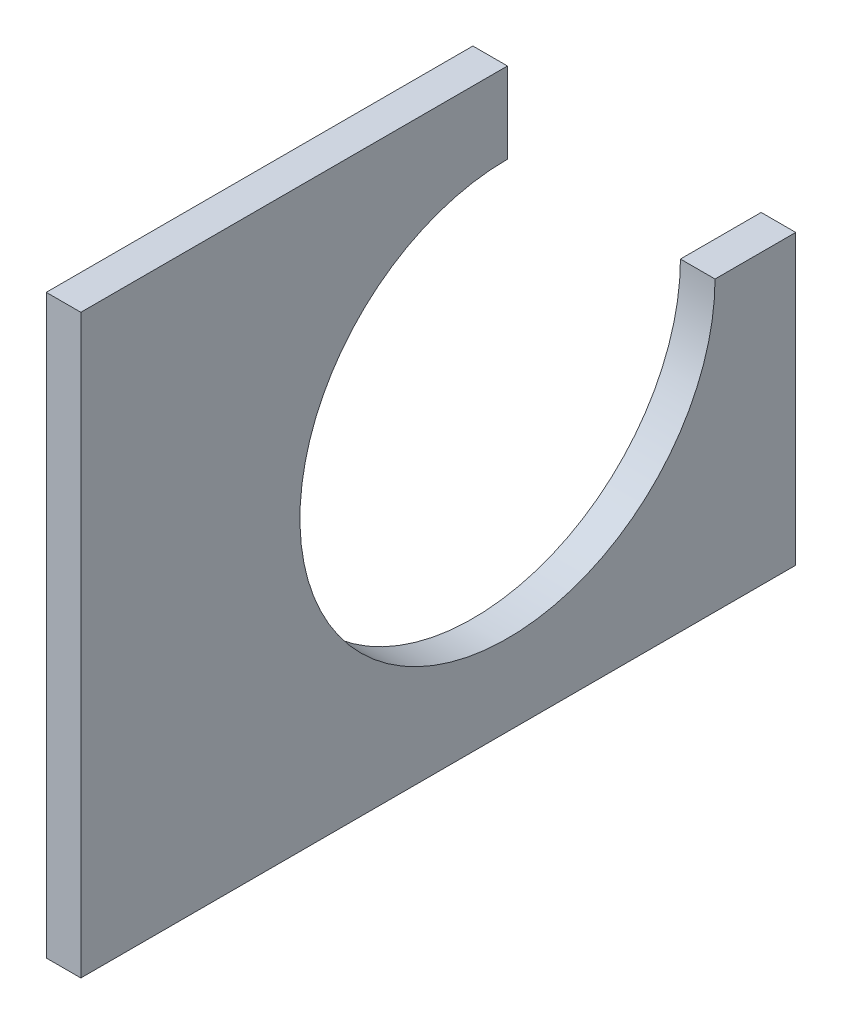
from build123d import *

# Parameters (mm, degrees)
BOSS_EXTRUDE1_DEPTH = 3


with BuildPart() as part:
    # Sketch1 → Boss-Extrude1 (new body)
    with BuildSketch(Plane(origin=(0, 0, 0), x_dir=(0, 0, -1), z_dir=(1, 0, 0))):
        with BuildLine():
            Line((0, 25), (0, 18))
            ThreePointArc((0, 18), (-12.727922061, -12.727922061), (18, 0))
            Line((18, 0), (25, 0))
            Line((25, 0), (25, -25))
            Line((25, -25), (-37, -25))
            Line((-37, -25), (-37, 25))
            Line((-37, 25), (0, 25))
        make_face()
    extrude(amount=BOSS_EXTRUDE1_DEPTH)


solid = part.part
